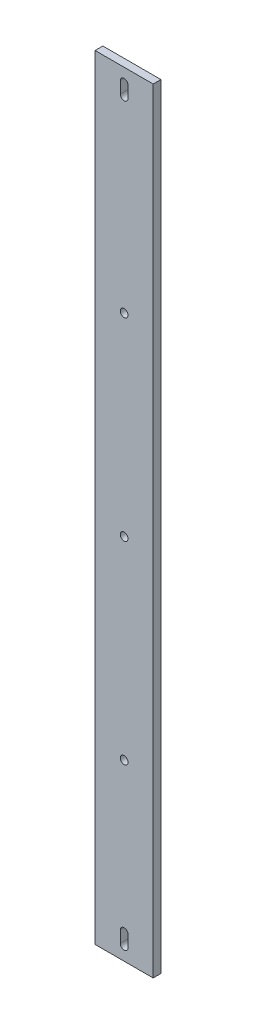
from build123d import *

# Parameters (mm, degrees)
ESQUISSE1_W             = 30
ESQUISSE1_H             = 400
BOSS_EXTRU_1_DEPTH      = 4
ESQUISSE2_R             = 2
ENL_V_MAT_EXTRU_1_DEPTH = 5


with BuildPart() as part:
    # Esquisse1 → Boss.-Extru.1 (new body)
    with BuildSketch(Plane.XY):
        with Locations((-37.589678395, -147.5)):
            Rectangle(ESQUISSE1_W, ESQUISSE1_H)
    extrude(amount=BOSS_EXTRU_1_DEPTH)

    # Esquisse2 → Enlèv. mat.-Extru.1 (cut, through all)
    with BuildSketch(Plane.XY.offset(4)):
        with Locations((-37.589678395, -57.5)):
            Circle(ESQUISSE2_R)
        with Locations((-37.589678395, -257.5)):
            Circle(ESQUISSE2_R)
        with Locations((-37.589678395, -157.5)):
            Circle(ESQUISSE2_R)
        with BuildLine():
            Line((-35.589678395, 45.5), (-35.589678395, 39.5))
            ThreePointArc((-35.589678395, 39.5), (-37.589678395, 37.5), (-39.589678395, 39.5))
            Line((-39.589678395, 39.5), (-39.589678395, 45.5))
            ThreePointArc((-39.589678395, 45.5), (-37.589678395, 47.5), (-35.589678395, 45.5))
        make_face()
        with BuildLine():
            Line((-35.589678395, -334.499998934), (-35.589678395, -340.500001066))
            ThreePointArc((-35.589678395, -340.500001066), (-37.589678395, -342.5), (-39.589678395, -340.500001066))
            Line((-39.589678395, -340.500001066), (-39.589678395, -334.499998934))
            ThreePointArc((-39.589678395, -334.499998934), (-37.589678395, -332.499998934), (-35.589678395, -334.499998934))
        make_face()
    extrude(amount=-ENL_V_MAT_EXTRU_1_DEPTH, mode=Mode.SUBTRACT)


solid = part.part
